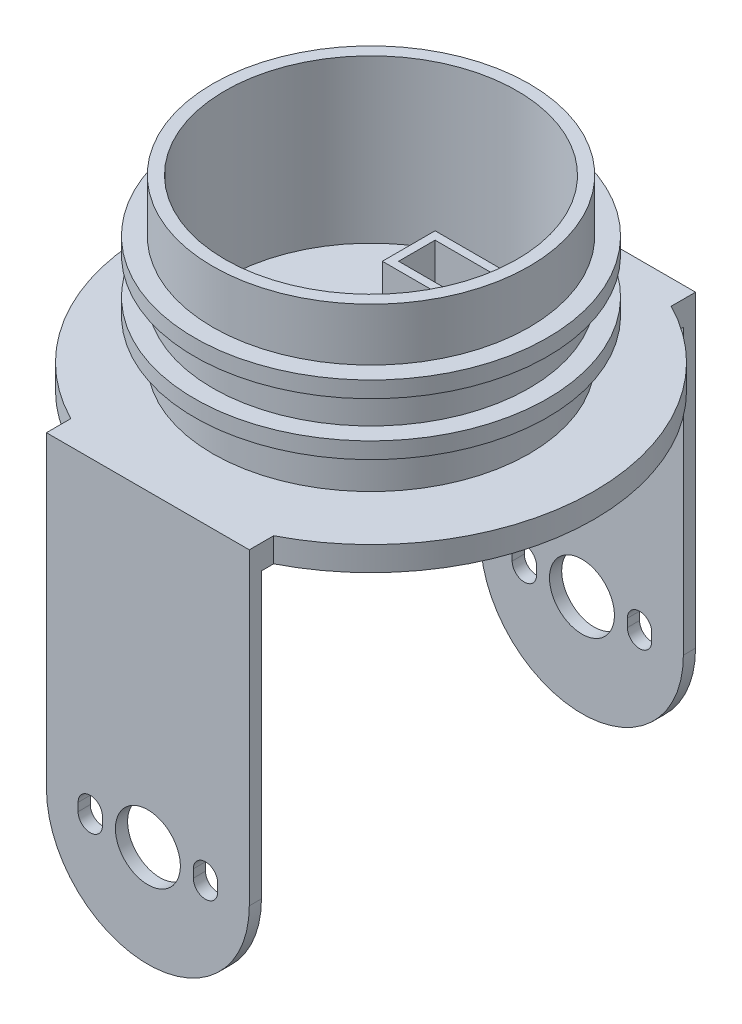
from build123d import *
from build123d.topology import SkipClean

# Parameters (mm, degrees)
SKETCH_1_R           = 19.5
SKETCH_1_R_2         = 18
EXTRUDE_1_DEPTH      = 20
SKETCH_3_R           = 27.5
EXTRUDE_2_DEPTH      = 3
EXTRUDE_START        = 2
SKETCH_25_R          = 21.75
SKETCH_25_R_2        = 19.5
EXTRUDE_12_DEPTH     = 2
EXTRUDE_START_2      = -1
SKETCH_26_R          = 21.75
SKETCH_26_R_2        = 19.5
EXTRUDE_13_DEPTH     = 2
SKETCH_27_W          = 25
SKETCH_27_H          = 53.5
EXTRUDE_14_DEPTH     = 3
SKETCH_28_R          = 4
EXTRUDE_17_DEPTH     = 1.5
EXTRUDE_START_3      = -53.5
SKETCH_28_25_R       = 4
EXTRUDE_25_DEPTH     = 53.5
CUT_EXTRUDE_START    = -52
SKETCH_28_27_R       = 4
CUT_EXTRUDE_15_DEPTH = 52
EXTRUDE_24_DEPTH     = 3
EXTRUDE_START_4      = -8
SKETCH_38_R          = 6.3
SKETCH_38_R_2        = 4.8
EXTRUDE_23_DEPTH     = 8
CUT_EXTRUDE_START_2  = -9.5
CUT_EXTRUDE_10_DEPTH = 9.5
SKETCH_34_W          = 10.2
SKETCH_34_H          = 6.5
SKETCH_34_W_2        = 8.2
SKETCH_34_H_2        = 4.5
EXTRUDE_22_DEPTH     = 5
SKETCH_37_W          = 8.2
SKETCH_37_H          = 4.5
CUT_EXTRUDE_9_DEPTH  = 5


with BuildPart() as part:
    # 草圖1 → 填料-伸長1 (new body)
    with BuildSketch(Plane(origin=(0, 0, 0), x_dir=(1, 0, 0), z_dir=(0, 1, 0))):
        Circle(SKETCH_1_R)
        Circle(SKETCH_1_R_2, mode=Mode.SUBTRACT)
    extrude(amount=EXTRUDE_1_DEPTH)

    # 草圖3 → 填料-伸長2 (add)
    with BuildSketch(Plane.XZ):
        Circle(SKETCH_3_R)
    extrude(amount=EXTRUDE_2_DEPTH)

    # 草圖25 → 填料-伸長12 (add)
    with BuildSketch(Plane(origin=(0, 7, 0), x_dir=(-1, 0, 0), z_dir=(0, -1, 0)).offset(EXTRUDE_START)):
        Circle(SKETCH_25_R)
        Circle(SKETCH_25_R_2, mode=Mode.SUBTRACT)
    extrude(amount=-EXTRUDE_12_DEPTH)

    # 草圖26 → 填料-伸長13 (add)
    with BuildSketch(Plane(origin=(0, 10.5, 0), x_dir=(-1, 0, 0), z_dir=(0, -1, 0)).offset(EXTRUDE_START_2)):
        Circle(SKETCH_26_R)
        Circle(SKETCH_26_R_2, mode=Mode.SUBTRACT)
    extrude(amount=-EXTRUDE_13_DEPTH)

    # 草圖27 → 填料-伸長14 (add)
    with BuildSketch(Plane.XZ.offset(3)):
        with Locations((0, 0.75)):
            Rectangle(SKETCH_27_W, SKETCH_27_H)
    extrude(amount=-EXTRUDE_14_DEPTH)

    # 草圖28 → 填料-伸長17 (add)
    with BuildSketch(Plane(origin=(0, 0, -26), x_dir=(-1, 0, 0), z_dir=(0, 0, -1))):
        with BuildLine():
            Line((12.5, 0), (-12.5, 0))
            Line((-12.5, 0), (-12.5, -38))
            ThreePointArc((-12.5, -38), (0, -50.5), (12.5, -38))
            Line((12.5, -38), (12.5, 0))
        make_face()
        with BuildLine():
            Line((8.6, -37.5), (8.6, -38.5))
            ThreePointArc((8.6, -38.5), (7.1, -40), (5.6, -38.5))
            Line((5.6, -38.5), (5.6, -37.5))
            ThreePointArc((5.6, -37.5), (7.1, -36), (8.6, -37.5))
        make_face(mode=Mode.SUBTRACT)
        with Locations((0, -38)):
            Circle(SKETCH_28_R, mode=Mode.SUBTRACT)
        with BuildLine():
            Line((-5.6, -37.5), (-5.6, -38.5))
            ThreePointArc((-5.6, -38.5), (-7.1, -40), (-8.6, -38.5))
            Line((-8.6, -38.5), (-8.6, -37.5))
            ThreePointArc((-8.6, -37.5), (-7.1, -36), (-5.6, -37.5))
        make_face(mode=Mode.SUBTRACT)
    extrude(amount=EXTRUDE_17_DEPTH)

    # 草圖28<25> → 填料-伸長25 (add)
    with BuildSketch(Plane(origin=(0, 0, -26), x_dir=(-1, 0, 0), z_dir=(0, 0, -1)).offset(EXTRUDE_START_3)):
        with BuildLine():
            Line((12.5, -38), (12.5, -3))
            Line((12.5, -3), (-12.5, -3))
            Line((-12.5, -3), (-12.5, -38))
            ThreePointArc((-12.5, -38), (0, -50.5), (12.5, -38))
        make_face()
        with BuildLine():
            Line((8.6, -37.5), (8.6, -38.5))
            ThreePointArc((8.6, -38.5), (7.1, -40), (5.6, -38.5))
            Line((5.6, -38.5), (5.6, -37.5))
            ThreePointArc((5.6, -37.5), (7.1, -36), (8.6, -37.5))
        make_face(mode=Mode.SUBTRACT)
        with Locations((0, -38)):
            Circle(SKETCH_28_25_R, mode=Mode.SUBTRACT)
        with BuildLine():
            Line((-5.6, -37.5), (-5.6, -38.5))
            ThreePointArc((-5.6, -38.5), (-7.1, -40), (-8.6, -38.5))
            Line((-8.6, -38.5), (-8.6, -37.5))
            ThreePointArc((-8.6, -37.5), (-7.1, -36), (-5.6, -37.5))
        make_face(mode=Mode.SUBTRACT)
    extrude(amount=EXTRUDE_25_DEPTH)

    # 草圖28<27> → 除料-伸長15 (cut)
    with BuildSketch(Plane(origin=(0, 0, -26), x_dir=(-1, 0, 0), z_dir=(0, 0, -1)).offset(CUT_EXTRUDE_START)):
        with BuildLine():
            Line((12.5, -38), (12.5, -3))
            Line((12.5, -3), (-12.5, -3))
            Line((-12.5, -3), (-12.5, -38))
            ThreePointArc((-12.5, -38), (0, -50.5), (12.5, -38))
        make_face()
        with BuildLine():
            Line((8.6, -37.5), (8.6, -38.5))
            ThreePointArc((8.6, -38.5), (7.1, -40), (5.6, -38.5))
            Line((5.6, -38.5), (5.6, -37.5))
            ThreePointArc((5.6, -37.5), (7.1, -36), (8.6, -37.5))
        make_face(mode=Mode.SUBTRACT)
        with Locations((0, -38)):
            Circle(SKETCH_28_27_R, mode=Mode.SUBTRACT)
        with BuildLine():
            Line((-5.6, -37.5), (-5.6, -38.5))
            ThreePointArc((-5.6, -38.5), (-7.1, -40), (-8.6, -38.5))
            Line((-8.6, -38.5), (-8.6, -37.5))
            ThreePointArc((-8.6, -37.5), (-7.1, -36), (-5.6, -37.5))
        make_face(mode=Mode.SUBTRACT)
    extrude(amount=CUT_EXTRUDE_15_DEPTH, mode=Mode.SUBTRACT)

    # 草圖38<4> → 填料-伸長24 (add)
    with BuildSketch(Plane(origin=(0, 0, -27.5), x_dir=(-1, 0, 0), z_dir=(0, 0, -1))):
        with BuildLine():
            Line((-1.3125, -15.961764662), (-1, -14.494677838))
            ThreePointArc((-1, -14.494677838), (-3.019933774, -6.069048379), (4.8, -9.8))
            ThreePointArc((4.8, -9.8), (3.730951621, -12.819933774), (1, -14.494677838))
            Line((1, -14.494677838), (1.3125, -15.961764662))
            ThreePointArc((1.3125, -15.961764662), (4.896874003, -13.763663079), (6.3, -9.8))
            ThreePointArc((6.3, -9.8), (-3.963663079, -4.903125997), (-1.3125, -15.961764662))
        make_face()
    extrude(amount=EXTRUDE_24_DEPTH)

    # 草圖38 → 填料-伸長23 (add)
    with BuildSketch(Plane(origin=(0, 0, -27.5), x_dir=(-1, 0, 0), z_dir=(0, 0, -1)).offset(EXTRUDE_START_4)):
        with Locations((0, -9.8)):
            Circle(SKETCH_38_R)
        with Locations((0, -9.8)):
            Circle(SKETCH_38_R_2, mode=Mode.SUBTRACT)
    extrude(amount=EXTRUDE_23_DEPTH)

    # 草圖38<3> → 除料-伸長10 (cut)
    with SkipClean():  # the faces are left unmerged after this step: merging them gives an invalid solid
        with BuildSketch(Plane(origin=(0, 0, -27.5), x_dir=(-1, 0, 0), z_dir=(0, 0, -1)).offset(CUT_EXTRUDE_START_2)):
            with BuildLine():
                ThreePointArc((4.8, -9.8), (-3.019933774, -6.069048379), (-1, -14.494677838))
                ThreePointArc((-1, -14.494677838), (0, -14.6), (1, -14.494677838))
                ThreePointArc((1, -14.494677838), (3.730951621, -12.819933774), (4.8, -9.8))
            make_face()
        extrude(amount=CUT_EXTRUDE_10_DEPTH, mode=Mode.SUBTRACT)

    # 草圖34 → 填料-伸長22 (add)
    with SkipClean():  # the faces are left unmerged after this step: merging them gives an invalid solid
        with BuildSketch(Plane(origin=(0, 0, 0), x_dir=(1, 0, 0), z_dir=(0, 1, 0))):
            with Locations((0, 9.75)):
                Rectangle(SKETCH_34_W, SKETCH_34_H)
            with Locations((0, 9.75)):
                Rectangle(SKETCH_34_W_2, SKETCH_34_H_2, mode=Mode.SUBTRACT)
        extrude(amount=EXTRUDE_22_DEPTH)

    # 草圖37 → 除料-伸長9 (cut)
    with SkipClean():  # the faces are left unmerged after this step: merging them gives an invalid solid
        with BuildSketch(Plane(origin=(0, 0, 0), x_dir=(1, 0, 0), z_dir=(0, 1, 0))):
            with Locations((0, 9.75)):
                Rectangle(SKETCH_37_W, SKETCH_37_H)
        extrude(amount=-CUT_EXTRUDE_9_DEPTH, mode=Mode.SUBTRACT)


solid = part.part
